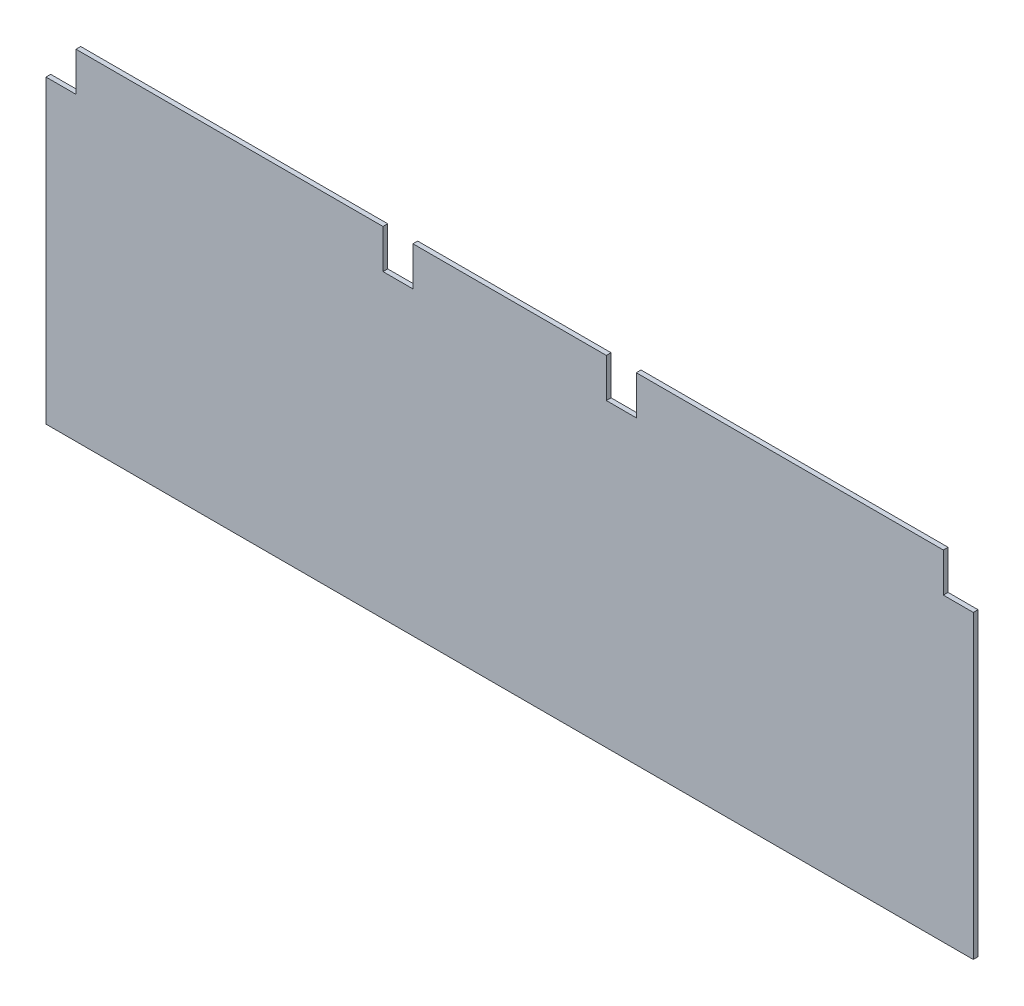
from build123d import *

# Parameters (mm, degrees)
CROQUIS1_W              = 196.4
CROQUIS1_H              = 71.948
SALIENTE_EXTRUIR1_DEPTH = 1
CROQUIS5_W              = 6.35
CROQUIS5_H              = 8.278
CORTAR_EXTRUIR2_DEPTH   = 2


with BuildPart() as part:
    # Croquis1 → Saliente-Extruir1 (new body)
    with BuildSketch(Plane.XY):
        Rectangle(CROQUIS1_W, CROQUIS1_H)
    extrude(amount=SALIENTE_EXTRUIR1_DEPTH)

    # Croquis5 → Cortar-Extruir2 (cut, through all)
    with BuildSketch(Plane(origin=(0, 0, 0), x_dir=(-1, 0, 0), z_dir=(0, 0, -1))):
        with Locations((-95.025, 31.835)):
            Rectangle(CROQUIS5_W, CROQUIS5_H)
        with Locations((-23.655, 31.835)):
            Rectangle(CROQUIS5_W, CROQUIS5_H)
        with Locations((23.655, 31.835)):
            Rectangle(CROQUIS5_W, CROQUIS5_H)
        with Locations((95.025, 31.835)):
            Rectangle(CROQUIS5_W, CROQUIS5_H)
    extrude(amount=-CORTAR_EXTRUIR2_DEPTH, mode=Mode.SUBTRACT)


solid = part.part
